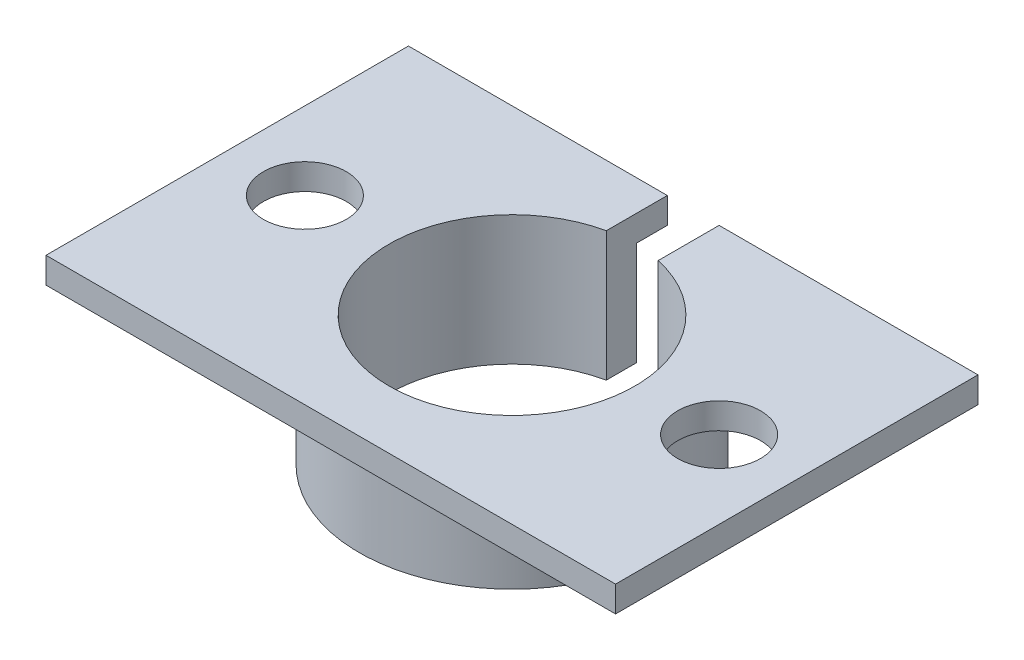
from build123d import *

# Parameters (mm, degrees)
SKETCH_1_W          = 22
SKETCH_1_H          = 14
EXTRUDE_1_DEPTH     = 1
SKETCH_2_R          = 4.75
CUT_EXTRUDE_1_DEPTH = 14.076696831
SKETCH_3_R          = 5.9
SKETCH_3_R_2        = 4.75
EXTRUDE_2_DEPTH     = 4
SKETCH_4_R          = 1.6
CUT_EXTRUDE_2_DEPTH = 1
SKETCH_5_W          = 2
SKETCH_5_H          = 7.900772946
CUT_EXTRUDE_3_DEPTH = 10


with BuildPart() as part:
    # 草图1 → 凸台-拉伸1 (new body)
    with BuildSketch(Plane(origin=(0, 0, 0), x_dir=(1, 0, 0), z_dir=(0, 1, 0))):
        Rectangle(SKETCH_1_W, SKETCH_1_H)
    extrude(amount=EXTRUDE_1_DEPTH)

    # 草图2 → 切除-拉伸1 (cut, through all)
    with BuildSketch(Plane(origin=(0, 1, 0), x_dir=(1, 0, 0), z_dir=(0, 1, 0))):
        with Locations(Location((0, 0, 0), (0, 0, 270))):
            Circle(SKETCH_2_R)
    extrude(amount=-CUT_EXTRUDE_1_DEPTH, mode=Mode.SUBTRACT)

    # 草图3 → 凸台-拉伸2 (add)
    with BuildSketch(Plane(origin=(0, 0, 0), x_dir=(-1, 0, 0), z_dir=(0, -1, 0))):
        with Locations(Location((0, 0, 0), (0, 0, 270))):
            Circle(SKETCH_3_R)
        with Locations(Location((0, 0, 0), (0, 0, 270))):
            Circle(SKETCH_3_R_2, mode=Mode.SUBTRACT)
    extrude(amount=EXTRUDE_2_DEPTH)

    # 草图4 → 切除-拉伸2 (cut)
    with BuildSketch(Plane(origin=(0, 1, 0), x_dir=(1, 0, 0), z_dir=(0, 1, 0))):
        with Locations(Location((8, 0, 0), (0, 0, 270))):
            Circle(SKETCH_4_R)
        with Locations(Location((-8, 0, 0), (0, 0, 270))):
            Circle(SKETCH_4_R)
    extrude(amount=-CUT_EXTRUDE_2_DEPTH, mode=Mode.SUBTRACT)

    # 草图5 → 切除-拉伸3 (cut)
    with BuildSketch(Plane(origin=(0, 1, 0), x_dir=(1, 0, 0), z_dir=(0, 1, 0))):
        with Locations((0, 3.95882741)):
            Rectangle(SKETCH_5_W, SKETCH_5_H)
    extrude(amount=-CUT_EXTRUDE_3_DEPTH, mode=Mode.SUBTRACT)


solid = part.part
